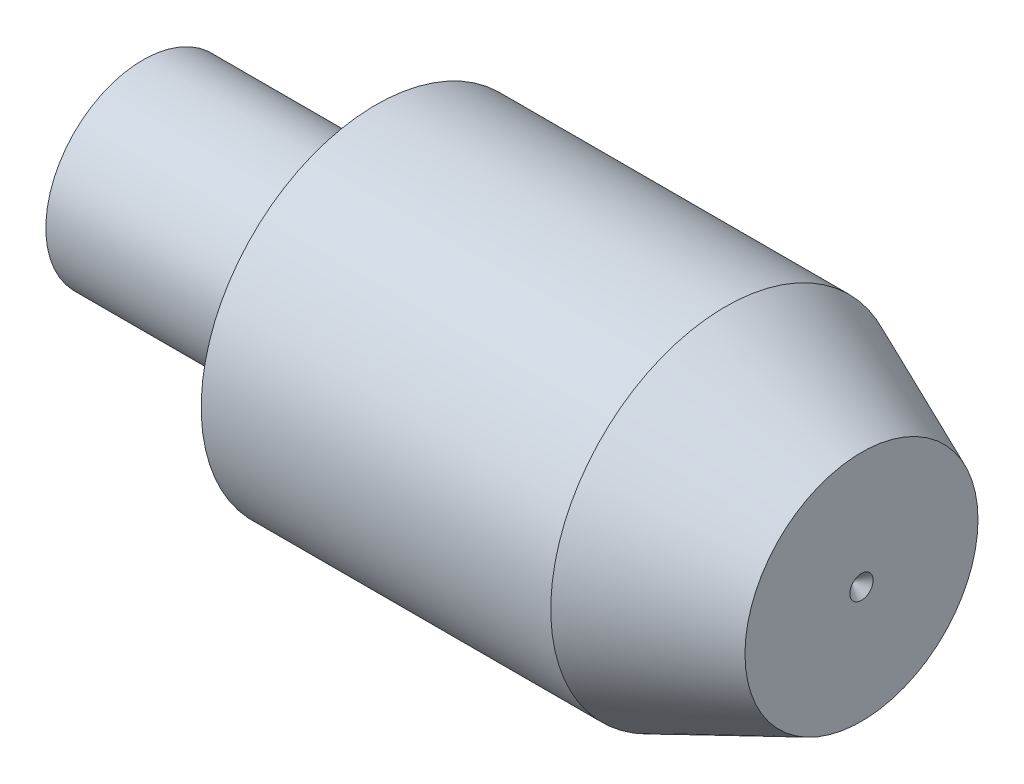
from build123d import *


with BuildPart() as part:
    # 草图1 → 旋转1 (revolve)
    with BuildSketch(Plane.XY, mode=Mode.PRIVATE) as revolve_1_sk:
        Polygon((0, 5), (0, 9), (18, 9), (25, 6), (25, 0), (0, 0), (-12, 0), (-12, 5), align=None)
    revolve(revolve_1_sk.sketch.rotate(Axis((25, 0, 0), (-1, 0, 0)), 90), axis=Axis((25, 0, 0), (-1, 0, 0)))

    # 切除-拉伸1 cone 1 section (through the dimple's axis) → 切除-拉伸1 (revolve, cut)
    with BuildSketch(Plane(origin=(25, 0, 0), x_dir=(0, 0, -1), z_dir=(0, 1, 0))):
        Polygon((0, 0), (0.6, 0), (0, 0.6), align=None)
    revolve(axis=Axis((25, 0, 0), (-1, 0, 0)), mode=Mode.SUBTRACT)


solid = part.part
